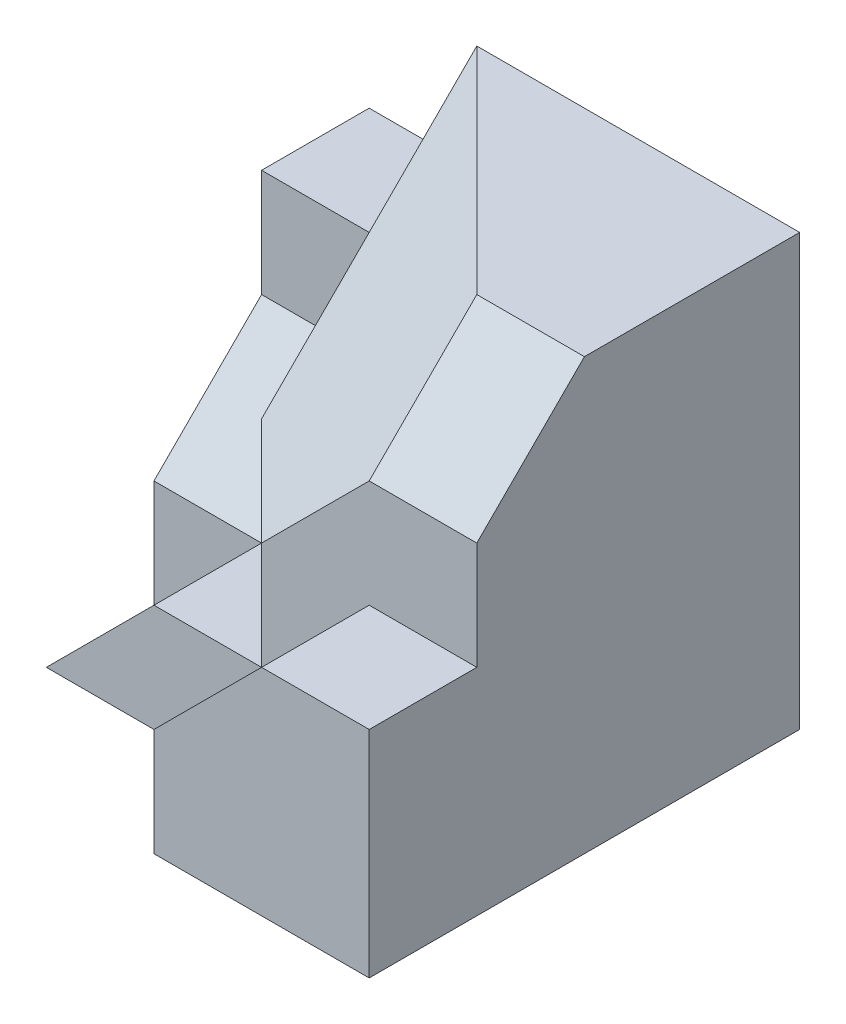
from build123d import *

# Parameters (mm, degrees)
BOSS_EXTRUDE1_DEPTH = 20
CUT_EXTRUDE5_DEPTH  = 30
BOSS_EXTRUDE5_DEPTH = 20
CUT_EXTRUDE9_DEPTH  = 22
CUT_EXTRUDE10_DEPTH = 22
BOSS_EXTRUDE6_DEPTH = 5
BOSS_EXTRUDE7_DEPTH = 5
BOSS_EXTRUDE8_DEPTH = 5
CUT_EXTRUDE11_DEPTH = 5


with BuildPart() as part:
    # Sketch1 → Boss-Extrude1 (new body)
    with BuildSketch(Plane(origin=(0, 0, 0), x_dir=(1, 0, 0), z_dir=(0, 1, 0))):
        Polygon((-15, 0), (0, 0), (0, -15), (-5, -15), (-5, -10), align=None)
    extrude(amount=BOSS_EXTRUDE1_DEPTH)

    # Sketch8 → Cut-Extrude5 (cut)
    with BuildSketch(Plane.ZY.offset(5)):
        Polygon((10, 20), (15, 15), (15, 20), align=None)
    extrude(amount=-CUT_EXTRUDE5_DEPTH, mode=Mode.SUBTRACT)

    # Sketch9 → Boss-Extrude5 (add)
    with BuildSketch(Plane(origin=(0, 0, 0), x_dir=(-1, 0, 0), z_dir=(0, -1, 0))):
        Polygon((15, 0), (5, -10), (5, -15), (15, -15), align=None)
    extrude(amount=-BOSS_EXTRUDE5_DEPTH)

    # 3DSketch3 → Cut-Extrude9 (cut, along a direction that is not the sketch's normal)
    with BuildSketch(Plane(origin=(-15, 20, 0), x_dir=(0.2672612419124245, -0.5345224838248489, 0.8017837257372732), z_dir=(-0.5773502691896256, 0.5773502691896258, 0.5773502691896258))):
        Polygon((0, 0), (10.690449676, 9.258200998), (17.371980724, 6.943650748), (18.708286934, 0), (13.363062096, -4.629100499), align=None)
    extrude(amount=CUT_EXTRUDE9_DEPTH, dir=(0, 0, 1), mode=Mode.SUBTRACT)

    # Sketch11 → Cut-Extrude10 (cut)
    with BuildSketch(Plane(origin=(0, 10, 0), x_dir=(1, 0, 0), z_dir=(0, 1, 0))):
        Polygon((-15, -10), (-10, -15), (-15, -15), align=None)
    extrude(amount=-CUT_EXTRUDE10_DEPTH, mode=Mode.SUBTRACT)

    # Sketch12 → Boss-Extrude6 (add)
    with BuildSketch(Plane.XY.offset(15)):
        Polygon((-5, 10), (0, 10), (0, 0), (-10, 0), (-10, 5), align=None)
    extrude(amount=BOSS_EXTRUDE6_DEPTH)

    # Sketch13 → Boss-Extrude7 (add)
    with BuildSketch(Plane.ZY.offset(15)):
        Polygon((0, 0), (0, 15), (5, 15), (5, 10), (10, 5), (10, 0), align=None)
    extrude(amount=BOSS_EXTRUDE7_DEPTH)

    # Sketch14 → Boss-Extrude8 (add)
    with BuildSketch(Plane(origin=(0, 0, 0), x_dir=(-1, 0, 0), z_dir=(0, -1, 0))):
        Polygon((20, -10), (15, -10), (10, -15), (20, -15), align=None)
    extrude(amount=-BOSS_EXTRUDE8_DEPTH)

    # Sketch15 → Cut-Extrude11 (cut)
    with BuildSketch(Plane.XY.offset(15)):
        Polygon((-20, 0), (-20, 5), (-15, 5), align=None)
    extrude(amount=-CUT_EXTRUDE11_DEPTH, mode=Mode.SUBTRACT)


solid = part.part
